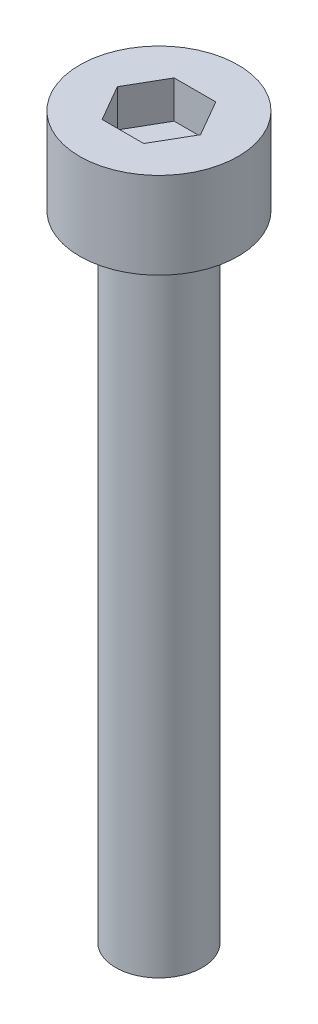
from build123d import *

# Parameters (mm, degrees)
SKETCH_1_R            = 2.75
EXTRUDE_248_DEPTH     = 3
CUT_EXTRUDE_378_DEPTH = 1.3
SKETCH_3_R            = 1.5
EXTRUDE_479_DEPTH     = 22


with BuildPart() as part:
    # 草图1 → Extrude 248 (new body)
    with BuildSketch(Plane(origin=(0, 0, 0), x_dir=(1, 0, 0), z_dir=(0, 1, 0))):
        Circle(SKETCH_1_R)
    extrude(amount=EXTRUDE_248_DEPTH)

    # 草图2 → Cut-Extrude 378 (cut)
    with BuildSketch(Plane(origin=(0, 3, 0), x_dir=(1, 0, 0), z_dir=(0, 1, 0))):
        Polygon((1.443375673, 0), (0.721687836, 1.25), (-0.721687836, 1.25), (-1.443375673, 0), (-0.721687836, -1.25), (0.721687836, -1.25), align=None)
    extrude(amount=-CUT_EXTRUDE_378_DEPTH, mode=Mode.SUBTRACT)

    # 草图3 → Extrude 479 (add)
    with BuildSketch(Plane.XZ):
        Circle(SKETCH_3_R)
    extrude(amount=EXTRUDE_479_DEPTH)


solid = part.part
